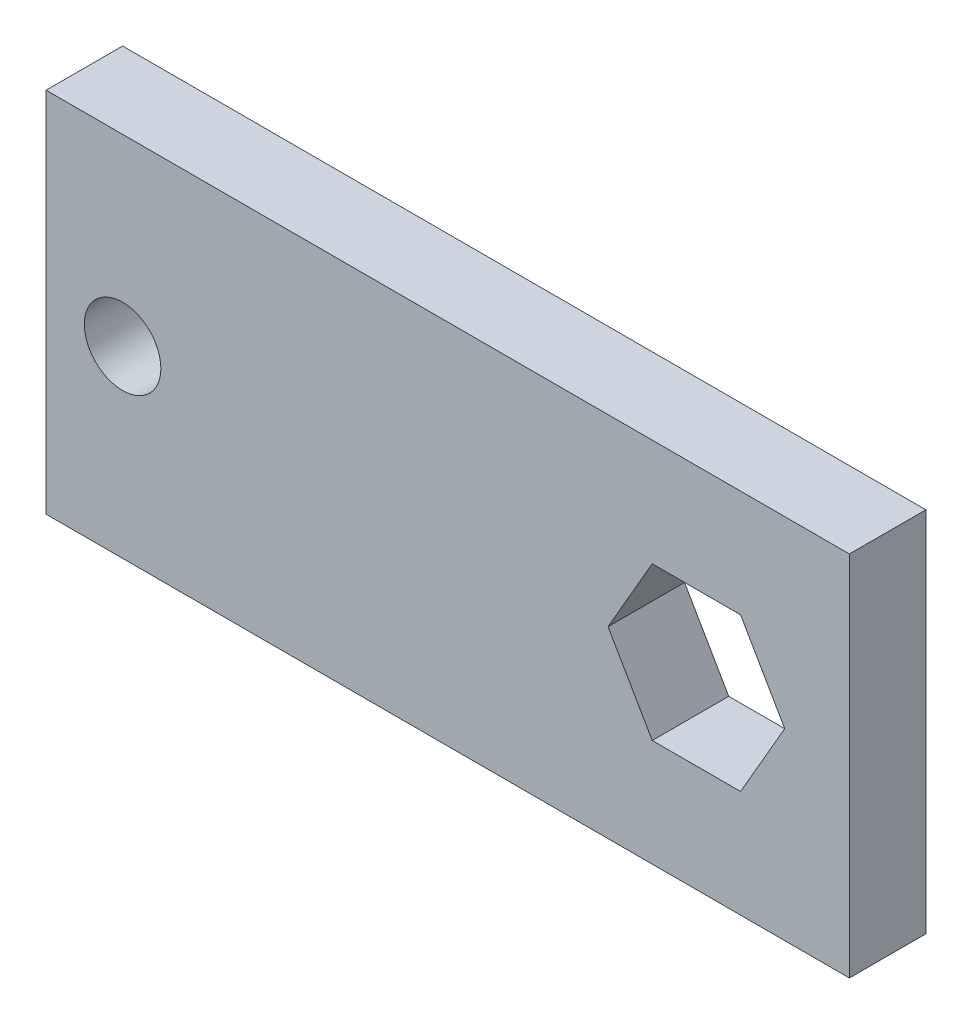
from build123d import *

# Parameters (mm, degrees)
SKETCH2_W           = 66.675
SKETCH2_H           = 30.48
SKETCH2_R           = 3.175
BOSS_EXTRUDE2_DEPTH = 6.35


with BuildPart() as part:
    # Sketch2 → Boss-Extrude2 (new body)
    with BuildSketch(Plane.XY):
        with Locations((-20.6375, 0)):
            Rectangle(SKETCH2_W, SKETCH2_H)
        with Locations((-47.625, 0)):
            Circle(SKETCH2_R, mode=Mode.SUBTRACT)
        Polygon((3.666174209, 6.35), (-3.666174209, 6.35), (-7.332348419, 0), (-3.666174209, -6.35), (3.666174209, -6.35), (7.332348419, 0), align=None, mode=Mode.SUBTRACT)
    extrude(amount=BOSS_EXTRUDE2_DEPTH)


solid = part.part
